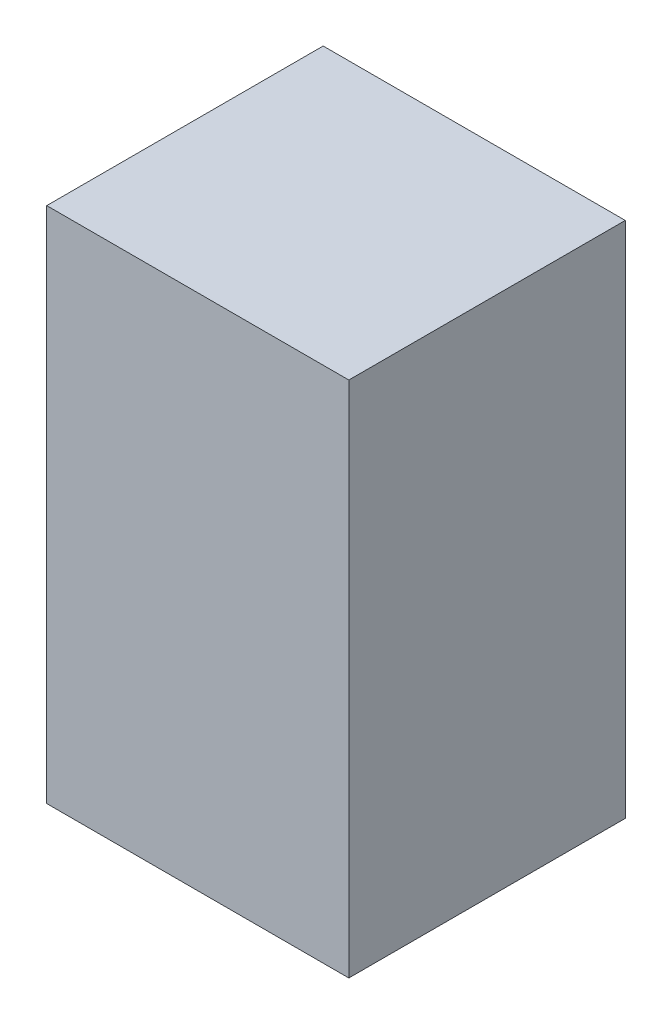
from build123d import *

# Parameters (mm, degrees)
SKETCH1_W           = 25.9
SKETCH1_H           = 44.4
BOSS_EXTRUDE1_DEPTH = 23.7


with BuildPart() as part:
    # Sketch1 → Boss-Extrude1 (new body)
    with BuildSketch(Plane.XY):
        with Locations((9.299090909, -6.911818182)):
            Rectangle(SKETCH1_W, SKETCH1_H)
    extrude(amount=BOSS_EXTRUDE1_DEPTH)


solid = part.part
